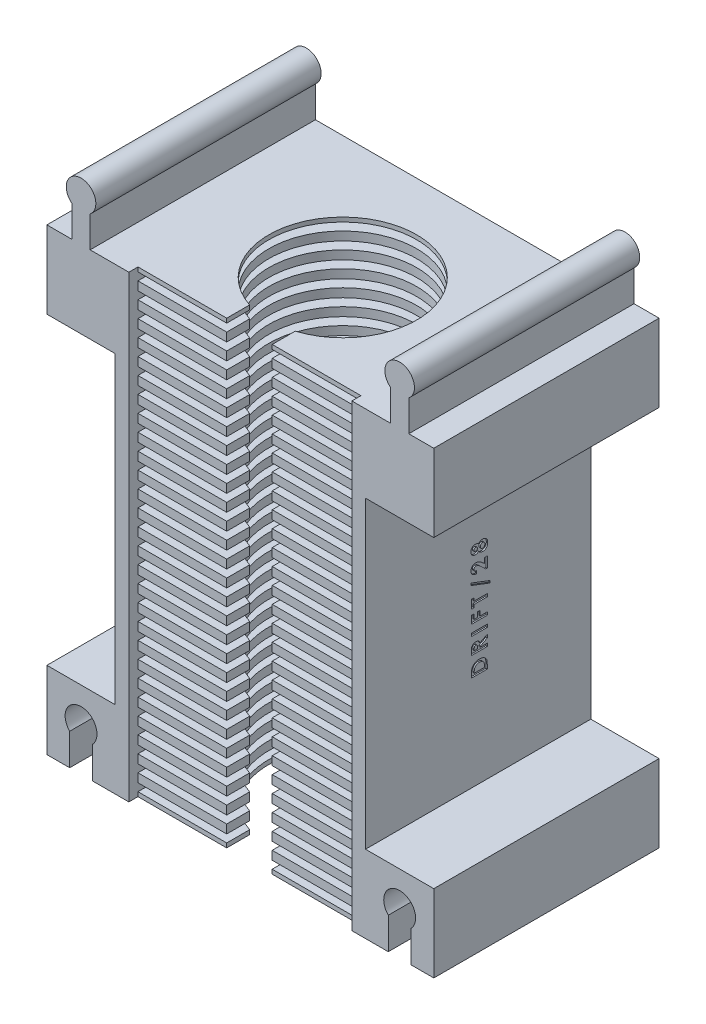
from build123d import *

# Parameters (mm, degrees)
ESQUISSE1_W              = 55
ESQUISSE1_H              = 109.5
BOSS_EXTRU_2_DEPTH       = 49.5
ESQUISSE6_W              = 49
ESQUISSE6_H              = 102.7
ENL_V_MAT_EXTRU_2_DEPTH  = 47
ESQUISSE7_W              = 49
ESQUISSE7_H              = 1.9
BOSS_EXTRU_3_DEPTH       = 45
ESQUISSE8_R              = 16.25
ENL_V_MAT_EXTRU_4_DEPTH  = 110.5
ESQUISSE9_W              = 10
ESQUISSE9_H              = 5.038353904
ENL_V_MAT_EXTRU_5_DEPTH  = 110.5
ESQUISSE11_W             = 15
ESQUISSE11_H             = 17.95
BOSS_EXTRU_4_DEPTH       = 49.5
ESQUISSE12_W             = 15
ESQUISSE12_H             = 17.95
BOSS_EXTRU_5_DEPTH       = 49.5
ENL_V_MAT_EXTRU_6_DEPTH  = 50.5
ESQUISSE16_W             = 5
ESQUISSE16_H             = 49.5
ENL_V_MAT_EXTRU_9_DEPTH  = 0.95
ESQUISSE17_W             = 55
ESQUISSE17_H             = 49.5
ENL_V_MAT_EXTRU_10_DEPTH = 7.75
ESQUISSE18_W             = 15
ESQUISSE18_H             = 17
BOSS_EXTRU_6_DEPTH       = 49.5
BOSS_EXTRU_7_DEPTH       = 49.5
ESQUISSE20_W             = 3.5
ESQUISSE20_H             = 0.628205128
ENL_V_MAT_EXTRU_11_DEPTH = 0.3


with BuildPart() as part:
    # Esquisse1 → Boss.-Extru.2 (new body)
    with BuildSketch(Plane.XY):
        with Locations((7.352262443, -30.443325792)):
            Rectangle(ESQUISSE1_W, ESQUISSE1_H)
    extrude(amount=BOSS_EXTRU_2_DEPTH)

    # Esquisse6 → Enlèv. mat.-Extru.2 (cut)
    with BuildSketch(Plane.XY.offset(49.5)):
        with Locations((7.352262443, -33.843325792)):
            Rectangle(ESQUISSE6_W, ESQUISSE6_H)
    extrude(amount=-ENL_V_MAT_EXTRU_2_DEPTH, mode=Mode.SUBTRACT)

    # Esquisse7 → Boss.-Extru.3 (add)
    with BuildSketch(Plane.XY.offset(2.5)):
        with Locations((7.352262443, -84.243325792)):
            Rectangle(ESQUISSE7_W, ESQUISSE7_H)
        with Locations((7.352262443, -80.643325792)):
            Rectangle(ESQUISSE7_W, ESQUISSE7_H)
        with Locations((7.352262443, -77.043325792)):
            Rectangle(ESQUISSE7_W, ESQUISSE7_H)
        with Locations((7.352262443, -73.443325792)):
            Rectangle(ESQUISSE7_W, ESQUISSE7_H)
        with Locations((7.352262443, -69.843325792)):
            Rectangle(ESQUISSE7_W, ESQUISSE7_H)
        with Locations((7.352262443, -66.243325792)):
            Rectangle(ESQUISSE7_W, ESQUISSE7_H)
        with Locations((7.352262443, -62.643325792)):
            Rectangle(ESQUISSE7_W, ESQUISSE7_H)
        with Locations((7.352262443, -59.043325792)):
            Rectangle(ESQUISSE7_W, ESQUISSE7_H)
        with Locations((7.352262443, -55.443325792)):
            Rectangle(ESQUISSE7_W, ESQUISSE7_H)
        with Locations((7.352262443, -51.843325792)):
            Rectangle(ESQUISSE7_W, ESQUISSE7_H)
        with Locations((7.352262443, -48.243325792)):
            Rectangle(ESQUISSE7_W, ESQUISSE7_H)
        with Locations((7.352262443, -44.643325792)):
            Rectangle(ESQUISSE7_W, ESQUISSE7_H)
        with Locations((7.352262443, -41.043325792)):
            Rectangle(ESQUISSE7_W, ESQUISSE7_H)
        with Locations((7.352262443, -37.443325792)):
            Rectangle(ESQUISSE7_W, ESQUISSE7_H)
        with Locations((7.352262443, -33.843325792)):
            Rectangle(ESQUISSE7_W, ESQUISSE7_H)
        with Locations((7.352262443, -30.243325792)):
            Rectangle(ESQUISSE7_W, ESQUISSE7_H)
        with Locations((7.352262443, -26.643325792)):
            Rectangle(ESQUISSE7_W, ESQUISSE7_H)
        with Locations((7.352262443, -23.043325792)):
            Rectangle(ESQUISSE7_W, ESQUISSE7_H)
        with Locations((7.352262443, -19.443325792)):
            Rectangle(ESQUISSE7_W, ESQUISSE7_H)
        with Locations((7.352262443, -15.843325792)):
            Rectangle(ESQUISSE7_W, ESQUISSE7_H)
        with Locations((7.352262443, -12.243325792)):
            Rectangle(ESQUISSE7_W, ESQUISSE7_H)
        with Locations((7.352262443, -8.643325792)):
            Rectangle(ESQUISSE7_W, ESQUISSE7_H)
        with Locations((7.352262443, -5.043325792)):
            Rectangle(ESQUISSE7_W, ESQUISSE7_H)
        with Locations((7.352262443, -1.443325792)):
            Rectangle(ESQUISSE7_W, ESQUISSE7_H)
        with Locations((7.352262443, 2.156674208)):
            Rectangle(ESQUISSE7_W, ESQUISSE7_H)
        with Locations((7.352262443, 5.756674208)):
            Rectangle(ESQUISSE7_W, ESQUISSE7_H)
        with Locations((7.352262443, 9.356674208)):
            Rectangle(ESQUISSE7_W, ESQUISSE7_H)
        with Locations((7.352262443, 12.956674208)):
            Rectangle(ESQUISSE7_W, ESQUISSE7_H)
        with Locations((7.352262443, 16.556674208)):
            Rectangle(ESQUISSE7_W, ESQUISSE7_H)
    extrude(amount=BOSS_EXTRU_3_DEPTH)

    # Esquisse8 → Enlèv. mat.-Extru.4 (cut, through all)
    with BuildSketch(Plane.XZ.offset(85.193325792)):
        with Locations((7.352262443, 27)):
            Circle(ESQUISSE8_R)
    extrude(amount=-ENL_V_MAT_EXTRU_4_DEPTH, mode=Mode.SUBTRACT)

    # Esquisse9 → Enlèv. mat.-Extru.5 (cut, through all)
    with BuildSketch(Plane.XZ.offset(85.193325792)):
        with Locations((7.352262443, 44.980823048)):
            Rectangle(ESQUISSE9_W, ESQUISSE9_H)
    extrude(amount=-ENL_V_MAT_EXTRU_5_DEPTH, mode=Mode.SUBTRACT)

    # Esquisse11 → Boss.-Extru.4 (add)
    with BuildSketch(Plane.XY.offset(49.5)):
        with Locations((42.352262443, -76.218325792)):
            Rectangle(ESQUISSE11_W, ESQUISSE11_H)
    extrude(amount=-BOSS_EXTRU_4_DEPTH)

    # Esquisse12 → Boss.-Extru.5 (add)
    with BuildSketch(Plane.XY.offset(49.5)):
        with Locations((-27.647737557, -76.218325792)):
            Rectangle(ESQUISSE12_W, ESQUISSE12_H)
    extrude(amount=-BOSS_EXTRU_5_DEPTH)

    # Esquisse13 → Enlèv. mat.-Extru.6 (cut, through all)
    with BuildSketch(Plane.XY.offset(49.5)):
        with BuildLine():
            Line((44.852262443, -85.193325792), (44.852262443, -77.293325792))
            ThreePointArc((44.852262443, -77.293325792), (42.352262443, -71.343836049), (39.852262443, -77.293325792))
            Line((39.852262443, -77.293325792), (39.852262443, -85.193325792))
            Line((39.852262443, -85.193325792), (44.852262443, -85.193325792))
        make_face()
        with BuildLine():
            Line((-30.147737557, -85.193325792), (-30.147737557, -77.293325792))
            ThreePointArc((-30.147737557, -77.293325792), (-27.647737557, -71.343836049), (-25.147737557, -77.293325792))
            Line((-25.147737557, -77.293325792), (-25.147737557, -85.193325792))
            Line((-25.147737557, -85.193325792), (-30.147737557, -85.193325792))
        make_face()
    extrude(amount=-ENL_V_MAT_EXTRU_6_DEPTH, mode=Mode.SUBTRACT)

    # Esquisse16 → Enlèv. mat.-Extru.9 (cut)
    with BuildSketch(Plane.XZ.offset(85.193325792)):
        with Locations((47.352262443, 24.75)):
            Rectangle(ESQUISSE16_W, ESQUISSE16_H)
        with Locations((-32.647737557, 24.75)):
            Rectangle(ESQUISSE16_W, ESQUISSE16_H)
        with BuildLine():
            Line((-25.147737557, 0), (39.852262443, 0))
            Line((39.852262443, 0), (39.852262443, 49.5))
            Line((39.852262443, 49.5), (31.852262443, 49.5))
            Line((31.852262443, 49.5), (31.852262443, 47.5))
            Line((31.852262443, 47.5), (12.352262443, 47.5))
            Line((12.352262443, 47.5), (12.352262443, 42.461646096))
            ThreePointArc((12.352262443, 42.461646096), (7.352262443, 10.75), (2.352262443, 42.461646096))
            Line((2.352262443, 42.461646096), (2.352262443, 47.5))
            Line((2.352262443, 47.5), (-17.147737557, 47.5))
            Line((-17.147737557, 47.5), (-17.147737557, 49.5))
            Line((-17.147737557, 49.5), (-25.147737557, 49.5))
            Line((-25.147737557, 49.5), (-25.147737557, 0))
        make_face()
    extrude(amount=-ENL_V_MAT_EXTRU_9_DEPTH, mode=Mode.SUBTRACT)

    # Esquisse17 → Enlèv. mat.-Extru.10 (cut)
    with BuildSketch(Plane(origin=(0, 24.306674208, 0), x_dir=(1, 0, 0), z_dir=(0, 1, 0))):
        with Locations((7.352262443, -24.75)):
            Rectangle(ESQUISSE17_W, ESQUISSE17_H)
    extrude(amount=-ENL_V_MAT_EXTRU_10_DEPTH, mode=Mode.SUBTRACT)

    # Esquisse18 → Boss.-Extru.6 (add)
    with BuildSketch(Plane.XY.offset(49.5)):
        with Locations((-27.647737557, 8.056674208)):
            Rectangle(ESQUISSE18_W, ESQUISSE18_H)
        with Locations((42.352262443, 8.056674208)):
            Rectangle(ESQUISSE18_W, ESQUISSE18_H)
    extrude(amount=-BOSS_EXTRU_6_DEPTH)

    # Esquisse19 → Boss.-Extru.7 (add)
    with BuildSketch(Plane.XY.offset(49.5)):
        with BuildLine():
            Line((-25.647737557, 16.556674208), (-25.647737557, 23.396674208))
            ThreePointArc((-25.647737557, 23.396674208), (-27.647737557, 29.2084119), (-29.647737557, 23.396674208))
            Line((-29.647737557, 23.396674208), (-29.647737557, 16.556674208))
            Line((-29.647737557, 16.556674208), (-25.647737557, 16.556674208))
        make_face()
        with BuildLine():
            Line((40.352262443, 16.556674208), (44.352262443, 16.556674208))
            Line((44.352262443, 16.556674208), (44.352262443, 23.396674208))
            ThreePointArc((44.352262443, 23.396674208), (42.352262443, 29.2084119), (40.352262443, 23.396674208))
            Line((40.352262443, 23.396674208), (40.352262443, 16.556674208))
        make_face()
    extrude(amount=-BOSS_EXTRU_7_DEPTH)

    # Esquisse20 → Enlèv. mat.-Extru.11 (cut)
    with BuildSketch(Plane(origin=(34.852262443, 0, 0), x_dir=(0, 0, -1), z_dir=(1, 0, 0))):
        with BuildLine():
            Line((-26.25, -46.331146305), (-26.25, -45.539579798))
            add(Edge.make_bspline(
                [(-26.25, -45.539579798), (-26.249578594, -45.477866572), (-26.248764011, -45.358574207), (-26.239233964, -45.185767762), (-26.225241045, -45.024959028), (-26.203820297, -44.876514303), (-26.178974202, -44.739890609), (-26.145644783, -44.616124289), (-26.107640591, -44.504317891), (-26.062804681, -44.40338554), (-26.010558183, -44.311239848), (-25.952352997, -44.223745665), (-25.886064826, -44.141073342), (-25.812970397, -44.062063093), (-25.731733047, -43.987734455), (-25.643698202, -43.916849619), (-25.547589281, -43.851144161), (-25.445710659, -43.788631948), (-25.337630589, -43.73209797), (-25.224269024, -43.682786922), (-25.106355489, -43.641478757), (-24.983764318, -43.607913735), (-24.856902477, -43.581158538), (-24.72551397, -43.562438466), (-24.589720442, -43.550865531), (-24.4976865, -43.549691554), (-24.450921474, -43.549095023)],
                knots=[0, 0, 0, 0, 0.000185117, 0.000357834, 0.000519065, 0.000669183, 0.000807653, 0.000935374, 0.001053334, 0.001161611, 0.001266144, 0.001370762, 0.001476536, 0.001583695, 0.001693351, 0.00180657, 0.001922483, 0.002042366, 0.002164984, 0.002288073, 0.002412914, 0.002539466, 0.002669135, 0.002801605, 0.002937385, 0.003077654, 0.003077654, 0.003077654, 0.003077654], degree=3))
            add(Edge.make_bspline(
                [(-24.450921474, -43.549095023), (-24.384932979, -43.550657062), (-24.255030763, -43.553732029), (-24.064400757, -43.579633833), (-23.881662884, -43.62152582), (-23.708246589, -43.680429758), (-23.545696172, -43.753454873), (-23.396878133, -43.84069155), (-23.262591281, -43.940860698), (-23.143504152, -44.052795331), (-23.04114743, -44.173993307), (-22.953485402, -44.299942339), (-22.884360039, -44.431869876), (-22.840513664, -44.54811532), (-22.813270001, -44.648917402), (-22.797083391, -44.737411224), (-22.782639367, -44.837999175), (-22.769738179, -44.951348242), (-22.761139953, -45.077447269), (-22.755119024, -45.216317598), (-22.750668347, -45.367777023), (-22.75022862, -45.472969702), (-22.75, -45.527660728)],
                knots=[0, 0, 0, 0, 0.000197895, 0.000389568, 0.000575968, 0.000759549, 0.000938093, 0.001109685, 0.001275991, 0.00143967, 0.001598838, 0.001751113, 0.001899136, 0.002044464, 0.002122868, 0.002212109, 0.002314138, 0.002427722, 0.002554253, 0.002693218, 0.002844719, 0.003008787, 0.003008787, 0.003008787, 0.003008787], degree=3))
            Line((-22.75, -45.527660728), (-22.75, -46.331146305))
            Line((-22.75, -46.331146305), (-26.25, -46.331146305))
        make_face()
        with BuildLine():
            Line((-25.621794872, -45.702941176), (-23.378205128, -45.702941176))
            Line((-23.378205128, -45.702941176), (-23.378205128, -45.374816176))
            add(Edge.make_bspline(
                [(-23.378205128, -45.374816176), (-23.378394152, -45.33578111), (-23.378757652, -45.26071505), (-23.383752105, -45.152204241), (-23.391862503, -45.052063523), (-23.403859003, -44.960161726), (-23.418293863, -44.876287573), (-23.436147882, -44.800747014), (-23.457859729, -44.733391161), (-23.483447361, -44.673664568), (-23.512661318, -44.619135507), (-23.546774213, -44.568618742), (-23.584684458, -44.519863909), (-23.627472703, -44.473772091), (-23.674581701, -44.430171713), (-23.726251594, -44.389319951), (-23.782325449, -44.35067176), (-23.843099544, -44.315219106), (-23.907932147, -44.282822285), (-23.976195242, -44.254082673), (-24.04845732, -44.230253294), (-24.124041919, -44.210447773), (-24.20360709, -44.196294483), (-24.286563503, -44.184585335), (-24.373239826, -44.178548928), (-24.432217292, -44.177720468), (-24.462139423, -44.177300151)],
                knots=[0, 0, 0, 0, 0.000117096, 0.00022518, 0.000325793, 0.00041841, 0.000503133, 0.000581017, 0.00065108, 0.000715155, 0.0007757, 0.00083637, 0.000897801, 0.000960813, 0.001024815, 0.001090185, 0.001158251, 0.001228957, 0.001301074, 0.001375555, 0.001450937, 0.001529162, 0.001609745, 0.001693235, 0.001780402, 0.001870171, 0.001870171, 0.001870171, 0.001870171], degree=3))
            add(Edge.make_bspline(
                [(-24.462139423, -44.177300151), (-24.507993301, -44.178134279), (-24.597404811, -44.179760763), (-24.727617239, -44.195544279), (-24.850078276, -44.220976128), (-24.964473331, -44.258023303), (-25.071529664, -44.30358164), (-25.169867721, -44.361510018), (-25.261099367, -44.428289281), (-25.314608967, -44.481127033), (-25.341346154, -44.507528516)],
                knots=[0, 0, 0, 0, 0.000137507, 0.000268129, 0.000392852, 0.000512141, 0.000628325, 0.00074112, 0.000853862, 0.000966454, 0.000966454, 0.000966454, 0.000966454], degree=3))
            add(Edge.make_bspline(
                [(-25.341346154, -44.507528516), (-25.364130624, -44.53356071), (-25.410665325, -44.586728519), (-25.466425797, -44.68007372), (-25.515416837, -44.782935296), (-25.554261268, -44.897666414), (-25.584981101, -45.023158246), (-25.606167818, -45.160158225), (-25.619782177, -45.307932687), (-25.6211096, -45.410307391), (-25.621794872, -45.463157523)],
                knots=[0, 0, 0, 0, 0.000103595, 0.000211582, 0.000324802, 0.000444978, 0.000574215, 0.000711958, 0.000860493, 0.001019003, 0.001019003, 0.001019003, 0.001019003], degree=3))
            Line((-25.621794872, -45.463157523), (-25.621794872, -45.702941176))
        make_face(mode=Mode.SUBTRACT)
        with BuildLine():
            Line((-26.25, -42.032428356), (-26.25, -41.300457202))
            add(Edge.make_bspline(
                [(-26.25, -41.300457202), (-26.249830799, -41.252073773), (-26.249505379, -41.159018811), (-26.244260781, -41.024844373), (-26.237121633, -40.901566425), (-26.225691304, -40.789123585), (-26.212215771, -40.687242739), (-26.194650202, -40.596250405), (-26.175000792, -40.515859992), (-26.150417474, -40.445491615), (-26.122731795, -40.381966658), (-26.090826593, -40.322820332), (-26.055389952, -40.26630623), (-26.014127668, -40.214245593), (-25.970721386, -40.163594739), (-25.922243734, -40.116847166), (-25.869536803, -40.073199687), (-25.812611126, -40.033440271), (-25.752669787, -39.996877876), (-25.689495986, -39.965426874), (-25.623603594, -39.93861171), (-25.55531745, -39.9160803), (-25.48395642, -39.899280821), (-25.410334289, -39.887777485), (-25.334062078, -39.87931373), (-25.282242845, -39.87882931), (-25.255809295, -39.878582202)],
                knots=[0, 0, 0, 0, 0.000145139, 0.000279143, 0.000402781, 0.00051552, 0.000618146, 0.000710961, 0.000793435, 0.000866163, 0.000934291, 0.001001103, 0.001067621, 0.001134095, 0.001200183, 0.001267615, 0.00133584, 0.001405283, 0.001475745, 0.001546294, 0.001616731, 0.001689011, 0.001761797, 0.001836373, 0.001912486, 0.001991741, 0.001991741, 0.001991741, 0.001991741], degree=3))
            add(Edge.make_bspline(
                [(-25.255809295, -39.878582202), (-25.228219651, -39.879228459), (-25.174121389, -39.88049565), (-25.09464501, -39.887264844), (-25.018423209, -39.89984957), (-24.945945132, -39.91828982), (-24.876468478, -39.940361715), (-24.811077599, -39.968946946), (-24.748615739, -40.001452755), (-24.69011221, -40.040015187), (-24.634309754, -40.082362224), (-24.583235096, -40.131543289), (-24.534467089, -40.184779455), (-24.489666455, -40.243690732), (-24.449112087, -40.308100747), (-24.411156725, -40.376798332), (-24.376474519, -40.450732889), (-24.357075547, -40.502666047), (-24.347155449, -40.529223228)],
                knots=[0, 0, 0, 0, 8.278e-05, 0.000162316, 0.000239082, 0.000314243, 0.000386523, 0.000457503, 0.000528069, 0.000597494, 0.000667473, 0.0007379, 0.00080987, 0.000883911, 0.00095957, 0.001038021, 0.00111926, 0.001204281, 0.001204281, 0.001204281, 0.001204281], degree=3))
            Line((-24.347155449, -40.529223228), (-22.75, -39.72153092))
            Line((-22.75, -39.72153092), (-22.75, -40.419848228))
            Line((-22.75, -40.419848228), (-24.275641026, -41.191082202))
            Line((-24.275641026, -41.191082202), (-24.275641026, -41.404223228))
            Line((-24.275641026, -41.404223228), (-22.75, -41.404223228))
            Line((-22.75, -41.404223228), (-22.75, -42.032428356))
            Line((-22.75, -42.032428356), (-26.25, -42.032428356))
        make_face()
        with BuildLine():
            Line((-24.903846154, -41.404223228), (-24.903846154, -41.159531721))
            add(Edge.make_bspline(
                [(-24.903846154, -41.159531721), (-24.904183083, -41.129616151), (-24.90482823, -41.072334261), (-24.90782069, -40.98995538), (-24.91503104, -40.91513571), (-24.924141047, -40.847553949), (-24.934659866, -40.786870034), (-24.949733972, -40.733625241), (-24.965886258, -40.686999152), (-24.98595936, -40.647544286), (-25.008786831, -40.613834955), (-25.034719405, -40.584729105), (-25.064733058, -40.560654394), (-25.098012147, -40.540839679), (-25.134851019, -40.525425985), (-25.174845265, -40.514175169), (-25.218450472, -40.507887627), (-25.248544002, -40.507164224), (-25.264222756, -40.50678733)],
                knots=[0, 0, 0, 0, 8.9755e-05, 0.000171861, 0.000247208, 0.00031513, 0.000376461, 0.000431743, 0.000480981, 0.000524253, 0.000564118, 0.000602839, 0.000640725, 0.000679082, 0.000718669, 0.000760178, 0.000803409, 0.000850432, 0.000850432, 0.000850432, 0.000850432], degree=3))
            add(Edge.make_bspline(
                [(-25.264222756, -40.50678733), (-25.282782236, -40.50746504), (-25.319012094, -40.508787993), (-25.371317394, -40.523092042), (-25.420078854, -40.544676764), (-25.464634662, -40.575227883), (-25.503578199, -40.613365199), (-25.537980978, -40.657143325), (-25.564881405, -40.707701924), (-25.583771508, -40.754055195), (-25.594375064, -40.796626009), (-25.602337473, -40.834913504), (-25.608254131, -40.879211699), (-25.613043563, -40.929745066), (-25.617318759, -40.986067241), (-25.6200393, -41.048730003), (-25.621237585, -41.117459739), (-25.621603761, -41.165374092), (-25.621794872, -41.19038108)],
                knots=[0, 0, 0, 0, 5.5548e-05, 0.000108435, 0.000161471, 0.000214949, 0.000269493, 0.000324467, 0.000381263, 0.000440763, 0.000474094, 0.000512732, 0.000558045, 0.000608066, 0.000665013, 0.000727476, 0.0007962, 0.000871223, 0.000871223, 0.000871223, 0.000871223], degree=3))
            Line((-25.621794872, -41.19038108), (-25.621794872, -41.404223228))
            Line((-25.621794872, -41.404223228), (-24.903846154, -41.404223228))
        make_face(mode=Mode.SUBTRACT)
        with Locations((-24.5, -38.092684766)):
            Rectangle(ESQUISSE20_W, ESQUISSE20_H)
        Polygon((-26.25, -36.082428356), (-26.25, -34.377300151), (-25.621794872, -34.377300151), (-25.621794872, -35.454223228), (-24.948717949, -35.454223228), (-24.948717949, -34.377300151), (-24.320512821, -34.377300151), (-24.320512821, -35.454223228), (-22.75, -35.454223228), (-22.75, -36.082428356), align=None)
        Polygon((-26.25, -33.219607843), (-26.25, -31.334992459), (-25.621794872, -31.334992459), (-25.621794872, -31.963197587), (-22.75, -31.963197587), (-22.75, -32.591402715), (-25.621794872, -32.591402715), (-25.621794872, -33.219607843), align=None)
        Polygon((-22.121794872, -30.267043741), (-26.33974359, -28.656566978), (-26.33974359, -28.180505279), (-22.121794872, -29.790982042), align=None)
        with BuildLine():
            Line((-25.083333333, -26.417043741), (-25.083333333, -27.045248869))
            add(Edge.make_bspline(
                [(-25.083333333, -27.045248869), (-25.130854225, -27.042536812), (-25.223707194, -27.037237617), (-25.358570766, -27.016135637), (-25.486033191, -26.987932364), (-25.605711269, -26.949970061), (-25.717655278, -26.903210969), (-25.821494412, -26.846491307), (-25.917972725, -26.781504524), (-26.00539818, -26.706940687), (-26.083996324, -26.625825983), (-26.152708884, -26.538368361), (-26.210230283, -26.444816257), (-26.257415349, -26.345795232), (-26.295169479, -26.24169423), (-26.320397882, -26.131461457), (-26.337486499, -26.016069573), (-26.33898158, -25.937073784), (-26.33974359, -25.896811369)],
                knots=[0, 0, 0, 0, 0.000142716, 0.000278858, 0.000408976, 0.000534035, 0.000655007, 0.000772346, 0.00088844, 0.001003349, 0.001116402, 0.001226781, 0.001336329, 0.001445148, 0.001555367, 0.001667776, 0.001783885, 0.001904578, 0.001904578, 0.001904578, 0.001904578], degree=3))
            add(Edge.make_bspline(
                [(-26.33974359, -25.896811369), (-26.338305172, -25.847367632), (-26.335495808, -25.750799457), (-26.308364005, -25.610944651), (-26.266816094, -25.47962898), (-26.206452711, -25.358249272), (-26.130333998, -25.247016559), (-26.039398207, -25.146549259), (-25.932540626, -25.058806804), (-25.81283848, -24.984473483), (-25.685837603, -24.923003744), (-25.55475327, -24.8795149), (-25.422968709, -24.851080766), (-25.33424216, -24.848041017), (-25.290164263, -24.84653092)],
                knots=[0, 0, 0, 0, 0.000148176, 0.000289401, 0.00042576, 0.000560275, 0.000694458, 0.000828966, 0.000965417, 0.001107812, 0.001250813, 0.001387611, 0.0015214, 0.001653479, 0.001653479, 0.001653479, 0.001653479], degree=3))
            add(Edge.make_bspline(
                [(-25.290164263, -24.84653092), (-25.263502321, -24.847118118), (-25.209838418, -24.848300003), (-25.12863176, -24.856517803), (-25.045913288, -24.868846131), (-24.961753913, -24.88743423), (-24.876130087, -24.910615167), (-24.788785397, -24.938736785), (-24.70021573, -24.972452389), (-24.609421581, -25.011195438), (-24.516118882, -25.057429039), (-24.41886483, -25.111207989), (-24.317762959, -25.17433024), (-24.211821602, -25.244740972), (-24.102658361, -25.325210161), (-23.989061065, -25.413606255), (-23.87120871, -25.510374217), (-23.792395337, -25.579000737), (-23.751903045, -25.614259285)],
                knots=[0, 0, 0, 0, 7.9977e-05, 0.000160974, 0.000244663, 0.00033075, 0.000419361, 0.000510712, 0.000605902, 0.000703579, 0.00080674, 0.00091815, 0.001036838, 0.001164207, 0.001299674, 0.001443567, 0.001595999, 0.001757068, 0.001757068, 0.001757068, 0.001757068], degree=3))
            Line((-23.751903045, -25.614259285), (-23.333333333, -25.979543741))
            Line((-23.333333333, -25.979543741), (-23.333333333, -24.801659125))
            Line((-23.333333333, -24.801659125), (-22.75, -24.801659125))
            Line((-22.75, -24.801659125), (-22.75, -27.134992459))
            Line((-22.75, -27.134992459), (-23.068309295, -27.134992459))
            Line((-23.068309295, -27.134992459), (-24.171173878, -26.098734446))
            add(Edge.make_bspline(
                [(-24.171173878, -26.098734446), (-24.20334446, -26.068731638), (-24.265649338, -26.010625097), (-24.357155907, -25.927953194), (-24.443974712, -25.853114892), (-24.527112566, -25.787783566), (-24.603754527, -25.728006482), (-24.676797956, -25.677998555), (-24.74418582, -25.634447778), (-24.826328946, -25.58895439), (-24.923559297, -25.54475636), (-25.035503417, -25.504227471), (-25.142571242, -25.479769954), (-25.212463844, -25.476368051), (-25.24599359, -25.474736048)],
                knots=[0, 0, 0, 0, 0.000131967, 0.000255582, 0.000369957, 0.000475731, 0.00057277, 0.000661456, 0.000741202, 0.000813387, 0.000942958, 0.001061149, 0.001170202, 0.001270758, 0.001270758, 0.001270758, 0.001270758], degree=3))
            add(Edge.make_bspline(
                [(-25.24599359, -25.474736048), (-25.278432191, -25.475953037), (-25.341287182, -25.478311149), (-25.430698073, -25.504224882), (-25.511650506, -25.544371336), (-25.581725534, -25.600943361), (-25.639310831, -25.6694698), (-25.682141156, -25.748658538), (-25.706854058, -25.837863952), (-25.709947231, -25.900398648), (-25.711538462, -25.93256858)],
                knots=[0, 0, 0, 0, 9.7062e-05, 0.000188073, 0.000276808, 0.000366596, 0.000456186, 0.000543702, 0.000634713, 0.000731135, 0.000731135, 0.000731135, 0.000731135], degree=3))
            add(Edge.make_bspline(
                [(-25.711538462, -25.93256858), (-25.710950642, -25.949187977), (-25.709793424, -25.981905929), (-25.702090139, -26.029998761), (-25.688513903, -26.075762546), (-25.670323658, -26.11970666), (-25.646212358, -26.16136212), (-25.616491338, -26.200623858), (-25.581915879, -26.237905546), (-25.542594092, -26.273036195), (-25.498710967, -26.305009672), (-25.450667285, -26.333408397), (-25.39849287, -26.356889415), (-25.342876502, -26.377562956), (-25.283220817, -26.393507381), (-25.219882848, -26.4051169), (-25.152965636, -26.413942842), (-25.106966346, -26.415991304), (-25.083333333, -26.417043741)],
                knots=[0, 0, 0, 0, 4.9859e-05, 9.8155e-05, 0.000145635, 0.000192772, 0.000240515, 0.000289593, 0.000340201, 0.000392836, 0.000447528, 0.000502841, 0.000559939, 0.000618941, 0.00068068, 0.000744897, 0.000812032, 0.000882971, 0.000882971, 0.000882971, 0.000882971], degree=3))
        make_face()
        with BuildLine():
            add(Edge.make_bspline(
                [(-24.634615385, -21.565841817), (-24.608399124, -21.529129493), (-24.556506402, -21.456460758), (-24.463516908, -21.360802542), (-24.360396474, -21.277679858), (-24.246567938, -21.20949511), (-24.125272331, -21.154420495), (-23.997775807, -21.115443475), (-23.865533106, -21.090354946), (-23.775620938, -21.087644635), (-23.730168269, -21.08627451)],
                knots=[0, 0, 0, 0, 0.000135177, 0.00026757, 0.000398747, 0.000531494, 0.000664547, 0.000797385, 0.000930644, 0.00106688, 0.00106688, 0.00106688, 0.00106688], degree=3))
            add(Edge.make_bspline(
                [(-23.730168269, -21.08627451), (-23.680952531, -21.087933849), (-23.58333943, -21.091224935), (-23.440207466, -21.120394959), (-23.302828224, -21.166981572), (-23.172829927, -21.23125115), (-23.053775925, -21.311451556), (-22.947586492, -21.404417018), (-22.858582453, -21.511543425), (-22.797907113, -21.610891838), (-22.758142228, -21.696730348), (-22.731097049, -21.765337661), (-22.709902083, -21.838752392), (-22.691352086, -21.91588049), (-22.677725438, -21.997686101), (-22.666880438, -22.083482987), (-22.661639156, -22.173882707), (-22.660725175, -22.235408236), (-22.66025641, -22.266963612)],
                knots=[0, 0, 0, 0, 0.000147517, 0.000292582, 0.000436255, 0.000581745, 0.000726227, 0.000865792, 0.001003678, 0.00114244, 0.001213641, 0.001287335, 0.001363423, 0.001442671, 0.001525201, 0.001612078, 0.001701997, 0.001796672, 0.001796672, 0.001796672, 0.001796672], degree=3))
            add(Edge.make_bspline(
                [(-22.66025641, -22.266963612), (-22.66071551, -22.300622996), (-22.661612041, -22.366353136), (-22.666968334, -22.462314366), (-22.677029661, -22.552797805), (-22.689701514, -22.638207746), (-22.708470894, -22.717780554), (-22.729085662, -22.792717244), (-22.754181324, -22.862218333), (-22.793392554, -22.946782935), (-22.852314869, -23.044308962), (-22.939580318, -23.148898316), (-23.042569555, -23.241865903), (-23.1604124, -23.321025111), (-23.290390869, -23.384870018), (-23.429594106, -23.43157024), (-23.577381299, -23.459438103), (-23.678633148, -23.462779126), (-23.730168269, -23.464479638)],
                knots=[0, 0, 0, 0, 0.000100983, 0.000197201, 0.000288177, 0.000374052, 0.000456032, 0.00053327, 0.000607128, 0.000677398, 0.000812671, 0.000947594, 0.001084602, 0.001227529, 0.00137208, 0.001517746, 0.00166681, 0.001821326, 0.001821326, 0.001821326, 0.001821326], degree=3))
            add(Edge.make_bspline(
                [(-23.730168269, -23.464479638), (-23.775121409, -23.462919919), (-23.863459772, -23.459854884), (-23.992919192, -23.437963849), (-24.115806027, -23.400189804), (-24.233038242, -23.348929945), (-24.344158312, -23.282446542), (-24.447922673, -23.200165688), (-24.546539694, -23.104315204), (-24.604769844, -23.03139947), (-24.634615385, -22.994026914)],
                knots=[0, 0, 0, 0, 0.000134836, 0.000264969, 0.000392498, 0.000519641, 0.000647939, 0.00077978, 0.000916124, 0.001059486, 0.001059486, 0.001059486, 0.001059486], degree=3))
            add(Edge.make_bspline(
                [(-24.634615385, -22.994026914), (-24.661328817, -23.017191541), (-24.713919521, -23.062795717), (-24.798578163, -23.121770875), (-24.885976136, -23.171702051), (-24.975561516, -23.213557064), (-25.068139115, -23.244814794), (-25.162495671, -23.268598037), (-25.259875268, -23.281837775), (-25.325650952, -23.283933772), (-25.358874199, -23.284992459)],
                knots=[0, 0, 0, 0, 0.000106018, 0.000208717, 0.000308899, 0.000407718, 0.000504832, 0.00060159, 0.000699257, 0.000798938, 0.000798938, 0.000798938, 0.000798938], degree=3))
            add(Edge.make_bspline(
                [(-25.358874199, -23.284992459), (-25.403852868, -23.283603368), (-25.492594051, -23.280862747), (-25.622527218, -23.256299623), (-25.746162643, -23.216079032), (-25.8627507, -23.160707825), (-25.969917282, -23.091033972), (-26.065239713, -23.007095825), (-26.147473394, -22.910305522), (-26.217453051, -22.801928648), (-26.272079533, -22.682098986), (-26.311215633, -22.552661964), (-26.335776289, -22.414427068), (-26.338401038, -22.319185166), (-26.33974359, -22.270469221)],
                knots=[0, 0, 0, 0, 0.000134836, 0.000266026, 0.000395067, 0.000523961, 0.000652113, 0.000777298, 0.000903613, 0.001031972, 0.00116311, 0.001297288, 0.00143676, 0.001582797, 0.001582797, 0.001582797, 0.001582797], degree=3))
            add(Edge.make_bspline(
                [(-26.33974359, -22.270469221), (-26.33839889, -22.222455018), (-26.335777008, -22.128837373), (-26.311378542, -21.993030426), (-26.271381317, -21.866400481), (-26.215576732, -21.749216858), (-26.145449257, -21.641967482), (-26.06040789, -21.546833389), (-25.962669968, -21.463155294), (-25.852739326, -21.392902964), (-25.734242443, -21.336410512), (-25.609753152, -21.295132498), (-25.480639208, -21.270926899), (-25.39309412, -21.267490311), (-25.349058494, -21.265761689)],
                knots=[0, 0, 0, 0, 0.000143937, 0.000280646, 0.000412357, 0.000541251, 0.000668816, 0.000795456, 0.000922759, 0.001053645, 0.001185674, 0.0013156, 0.001446101, 0.00157818, 0.00157818, 0.00157818, 0.00157818], degree=3))
            add(Edge.make_bspline(
                [(-25.349058494, -21.265761689), (-25.317938351, -21.266598046), (-25.256867397, -21.268239333), (-25.166892646, -21.28037468), (-25.080561752, -21.300809115), (-24.995788452, -21.329299343), (-24.910268983, -21.368910487), (-24.822364636, -21.422513574), (-24.728422968, -21.487714691), (-24.666940066, -21.538920385), (-24.634615385, -21.565841817)],
                knots=[0, 0, 0, 0, 9.3344e-05, 0.000183181, 0.000271783, 0.00035914, 0.000451054, 0.000553861, 0.000667646, 0.000793787, 0.000793787, 0.000793787, 0.000793787], degree=3))
        make_face()
        with BuildLine():
            add(Edge.make_bspline(
                [(-25.711538462, -22.285893901), (-25.710308493, -22.311767353), (-25.707915931, -22.362096933), (-25.685820835, -22.433653562), (-25.650979905, -22.498573648), (-25.601492169, -22.55444307), (-25.541179501, -22.599789546), (-25.472376685, -22.633672439), (-25.39550137, -22.653578655), (-25.341696997, -22.655696973), (-25.314002404, -22.65678733)],
                knots=[0, 0, 0, 0, 7.7441e-05, 0.000150641, 0.000222488, 0.000297018, 0.000372599, 0.000447541, 0.000525765, 0.000608738, 0.000608738, 0.000608738, 0.000608738], degree=3))
            add(Edge.make_bspline(
                [(-25.314002404, -22.65678733), (-25.286067572, -22.655445494), (-25.23152212, -22.652825429), (-25.1532216, -22.632188129), (-25.082161269, -22.597097059), (-25.020175989, -22.548520255), (-24.968327913, -22.490624925), (-24.930945649, -22.424099038), (-24.907231427, -22.351285204), (-24.904990138, -22.300100306), (-24.903846154, -22.27397483)],
                knots=[0, 0, 0, 0, 8.3728e-05, 0.000163486, 0.000240934, 0.00031989, 0.000398378, 0.000472472, 0.000547423, 0.000625563, 0.000625563, 0.000625563, 0.000625563], degree=3))
            add(Edge.make_bspline(
                [(-24.903846154, -22.27397483), (-24.905052171, -22.247406724), (-24.907401718, -22.195647069), (-24.929911463, -22.121816606), (-24.967192145, -22.055900471), (-25.018333035, -21.999170618), (-25.079997433, -21.951718466), (-25.152159356, -21.917710826), (-25.2330348, -21.897953474), (-25.28958494, -21.895328207), (-25.318910256, -21.893966817)],
                knots=[0, 0, 0, 0, 7.9536e-05, 0.000154952, 0.000229045, 0.000305029, 0.000382575, 0.000460979, 0.000542601, 0.000630522, 0.000630522, 0.000630522, 0.000630522], degree=3))
            add(Edge.make_bspline(
                [(-25.318910256, -21.893966817), (-25.346588717, -21.895366056), (-25.400117887, -21.898072134), (-25.476968269, -21.917475749), (-25.544638052, -21.953111459), (-25.604058384, -21.999932184), (-25.651977186, -22.058632826), (-25.687216962, -22.126779971), (-25.707656374, -22.203871813), (-25.71021641, -22.25796114), (-25.711538462, -22.285893901)],
                knots=[0, 0, 0, 0, 8.3029e-05, 0.000160575, 0.00023552, 0.000310854, 0.000386083, 0.000461028, 0.000539431, 0.000623159, 0.000623159, 0.000623159, 0.000623159], degree=3))
        make_face(mode=Mode.SUBTRACT)
        with BuildLine():
            add(Edge.make_bspline(
                [(-24.275641026, -22.265561369), (-24.275322008, -22.285218848), (-24.274693228, -22.323963492), (-24.267168754, -22.380879879), (-24.256486664, -22.435722697), (-24.239844164, -22.487531015), (-24.22040261, -22.537677346), (-24.195014548, -22.584895858), (-24.165522971, -22.629995586), (-24.131917754, -22.672003364), (-24.095068721, -22.709980441), (-24.056627337, -22.744210218), (-24.015610791, -22.772188959), (-23.973379718, -22.795488391), (-23.929600169, -22.814209665), (-23.883551002, -22.82658583), (-23.83584551, -22.834554351), (-23.803350461, -22.83569775), (-23.786959135, -22.83627451)],
                knots=[0, 0, 0, 0, 5.8932e-05, 0.000116154, 0.00017198, 0.000226311, 0.00027917, 0.000333116, 0.000386787, 0.00044066, 0.000494212, 0.000545394, 0.000594792, 0.000642802, 0.000689939, 0.000737227, 0.000785523, 0.000834682, 0.000834682, 0.000834682, 0.000834682], degree=3))
            add(Edge.make_bspline(
                [(-23.786959135, -22.83627451), (-23.7698646, -22.835999616), (-23.735959706, -22.835454398), (-23.686472771, -22.827219646), (-23.638746032, -22.815363054), (-23.593226189, -22.798710107), (-23.549939929, -22.776439895), (-23.508465714, -22.749849078), (-23.46909707, -22.718009409), (-23.432034579, -22.681788193), (-23.398628865, -22.641226245), (-23.369081394, -22.597555596), (-23.343425931, -22.551060878), (-23.323380973, -22.501300409), (-23.307663918, -22.448471606), (-23.296894747, -22.392803908), (-23.289362808, -22.334007291), (-23.28876711, -22.293865195), (-23.288461538, -22.273273709)],
                knots=[0, 0, 0, 0, 5.1225e-05, 0.000101599, 0.000150062, 0.000198643, 0.000246617, 0.00029582, 0.000346189, 0.000398247, 0.000451032, 0.000503536, 0.000556247, 0.000610019, 0.000664146, 0.000721346, 0.00077996, 0.000841695, 0.000841695, 0.000841695, 0.000841695], degree=3))
            add(Edge.make_bspline(
                [(-23.288461538, -22.273273709), (-23.288838882, -22.252456197), (-23.289574204, -22.211889461), (-23.296073027, -22.152589027), (-23.30638485, -22.096501427), (-23.321132878, -22.043693261), (-23.340026657, -21.993966229), (-23.364071205, -21.947982367), (-23.391332687, -21.904710062), (-23.423136771, -21.865473637), (-23.457834733, -21.829965923), (-23.495245044, -21.798679903), (-23.535473514, -21.772488222), (-23.578534112, -21.75167324), (-23.623481563, -21.734551045), (-23.670996908, -21.722645773), (-23.721063872, -21.715460044), (-23.755383906, -21.714811389), (-23.772936699, -21.714479638)],
                knots=[0, 0, 0, 0, 6.2435e-05, 0.000121667, 0.000178734, 0.00023334, 0.000285943, 0.000337996, 0.000388759, 0.000439127, 0.000489202, 0.000537499, 0.000585144, 0.000632805, 0.000680728, 0.000729191, 0.000779462, 0.000832089, 0.000832089, 0.000832089, 0.000832089], degree=3))
            add(Edge.make_bspline(
                [(-23.772936699, -21.714479638), (-23.790482865, -21.715121017), (-23.82477954, -21.716374692), (-23.875426643, -21.723234615), (-23.923440901, -21.736103126), (-23.96993583, -21.752938915), (-24.013949492, -21.775334314), (-24.055388254, -21.803137963), (-24.095281453, -21.83478442), (-24.131842247, -21.871775735), (-24.16530445, -21.912206546), (-24.194995597, -21.955288089), (-24.220538406, -22.000579195), (-24.239824276, -22.049192241), (-24.256492221, -22.099584413), (-24.267168811, -22.153039291), (-24.274694789, -22.208555995), (-24.275322476, -22.246370568), (-24.275641026, -22.265561369)],
                knots=[0, 0, 0, 0, 5.2659e-05, 0.00010293, 0.000152926, 0.000201506, 0.000251049, 0.000300635, 0.000351004, 0.000403555, 0.00045634, 0.000508266, 0.000560361, 0.000611921, 0.000664915, 0.000719368, 0.000775199, 0.00083273, 0.00083273, 0.00083273, 0.00083273], degree=3))
        make_face(mode=Mode.SUBTRACT)
    extrude(amount=-ENL_V_MAT_EXTRU_11_DEPTH, mode=Mode.SUBTRACT)


solid = part.part
